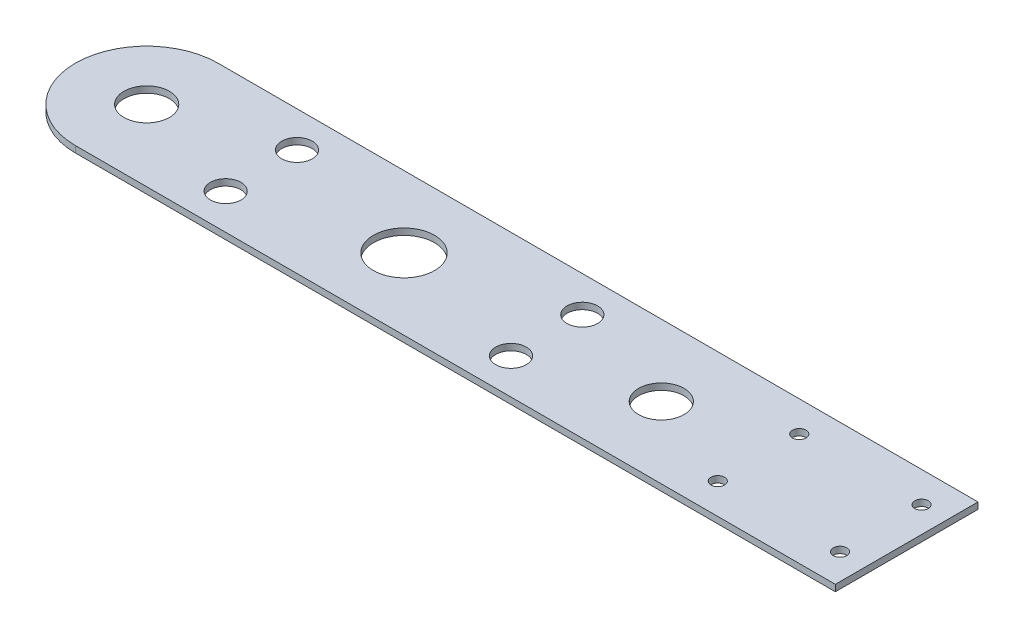
from build123d import *

# Parameters (mm, degrees)
SKETCH1_R           = 11.15
SKETCH1_R_2         = 7.5
SKETCH1_R_3         = 3.325
BOSS_EXTRUDE1_DEPTH = 3.175


with BuildPart() as part:
    # Sketch1 → Boss-Extrude1 (new body)
    with BuildSketch(Plane(origin=(0, 0, 0), x_dir=(1, 0, 0), z_dir=(0, 1, 0))):
        with BuildLine():
            ThreePointArc((-126.258214395, 35), (-161.258214395, 0), (-126.258214395, -35))
            Line((-126.258214395, -35), (246.658214395, -35))
            Line((246.658214395, -35), (246.658214395, 35))
            Line((246.658214395, 35), (-126.258214395, 35))
        make_face()
        with Locations((-126.258214395, 0)):
            Circle(SKETCH1_R, mode=Mode.SUBTRACT)
        with Locations((-70, -17.5)):
            Circle(SKETCH1_R_2, mode=Mode.SUBTRACT)
        with BuildLine():
            ThreePointArc((15, 0), (0, -15), (-15, 0))
            ThreePointArc((-15, 0), (0, 15), (15, 0))
        make_face(mode=Mode.SUBTRACT)
        with Locations((70, -17.5)):
            Circle(SKETCH1_R_2, mode=Mode.SUBTRACT)
        with Locations((173.958214395, -20)):
            Circle(SKETCH1_R_3, mode=Mode.SUBTRACT)
        with Locations((233.958214395, -20)):
            Circle(SKETCH1_R_3, mode=Mode.SUBTRACT)
        with Locations((-70, 17.5)):
            Circle(SKETCH1_R_2, mode=Mode.SUBTRACT)
        with Locations((126.258214395, 0)):
            Circle(SKETCH1_R, mode=Mode.SUBTRACT)
        with Locations((70, 17.5)):
            Circle(SKETCH1_R_2, mode=Mode.SUBTRACT)
        with Locations((173.958214395, 20)):
            Circle(SKETCH1_R_3, mode=Mode.SUBTRACT)
        with Locations((233.958214395, 20)):
            Circle(SKETCH1_R_3, mode=Mode.SUBTRACT)
    extrude(amount=BOSS_EXTRUDE1_DEPTH)


solid = part.part
